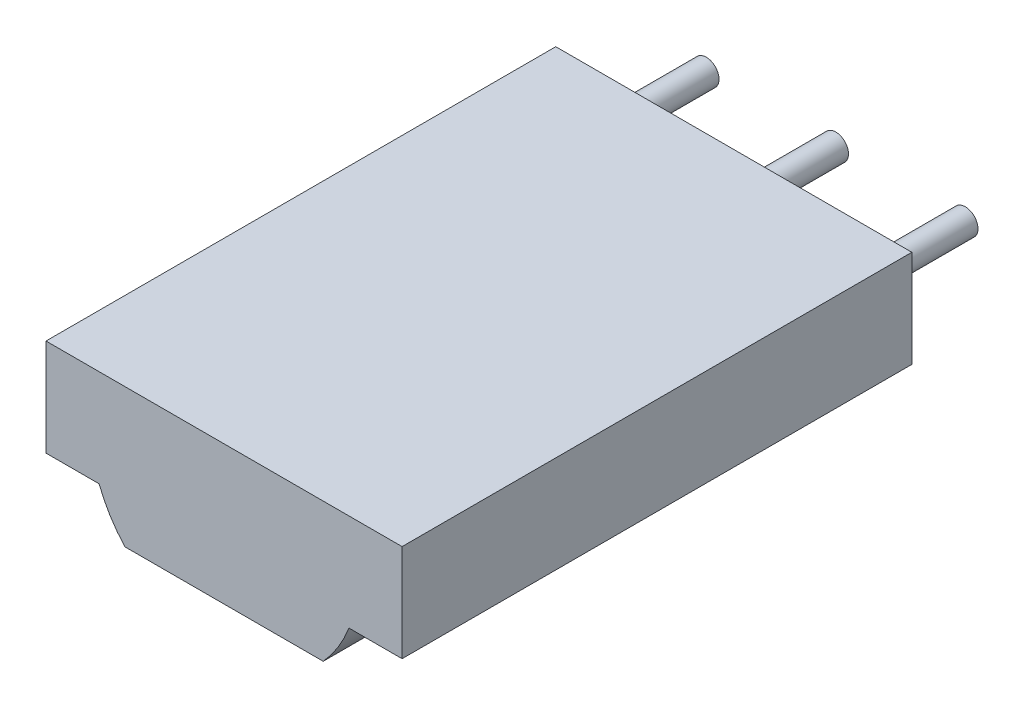
from build123d import *

# Parameters (mm, degrees)
COMPONENT_OUTLINE_DEPTH = 10
SKETCH2_R               = 0.25
EXTRUDE_1_DEPTH         = 2
SKETCH3_R               = 0.25
EXTRUDE_2_DEPTH         = 2
SKETCH4_R               = 0.25
EXTRUDE_3_DEPTH         = 2


with BuildPart() as part:
    # Sketch1 → Component_Outline (new body)
    with BuildSketch(Plane.XY):
        with BuildLine():
            Line((0.0885, 0.9525), (-0.9525, 0.9525))
            Line((-0.9525, 0.9525), (-0.9525, -0.9525))
            Line((-0.9525, -0.9525), (0.0885, -0.9525))
            ThreePointArc((0.0885, -0.9525), (0.303922623, -1.384580016), (0.5947, -1.77))
            Line((0.5947, -1.77), (4.4852, -1.77))
            ThreePointArc((4.4852, -1.77), (4.775977377, -1.384580016), (4.9914, -0.9525))
            Line((4.9914, -0.9525), (6.0325, -0.9525))
            Line((6.0325, -0.9525), (6.0325, 0.9525))
            Line((6.0325, 0.9525), (4.9914, 0.9525))
            Line((4.9914, 0.9525), (0.0885, 0.9525))
        make_face()
    extrude(amount=COMPONENT_OUTLINE_DEPTH)


with BuildPart() as body_2:
    # Sketch2 → Extrude 1 (new body)
    with BuildSketch(Plane.XY):
        Circle(SKETCH2_R)
    extrude(amount=-EXTRUDE_1_DEPTH)


with BuildPart() as body_3:
    # Sketch3 → Extrude 2 (new body)
    with BuildSketch(Plane.XY):
        with Locations((2.54, 0)):
            Circle(SKETCH3_R)
    extrude(amount=-EXTRUDE_2_DEPTH)


with BuildPart() as body_4:
    # Sketch4 → Extrude 3 (new body)
    with BuildSketch(Plane.XY):
        with Locations((5.08, 0)):
            Circle(SKETCH4_R)
    extrude(amount=-EXTRUDE_3_DEPTH)


solid = Compound([part.part, body_2.part, body_3.part, body_4.part])
